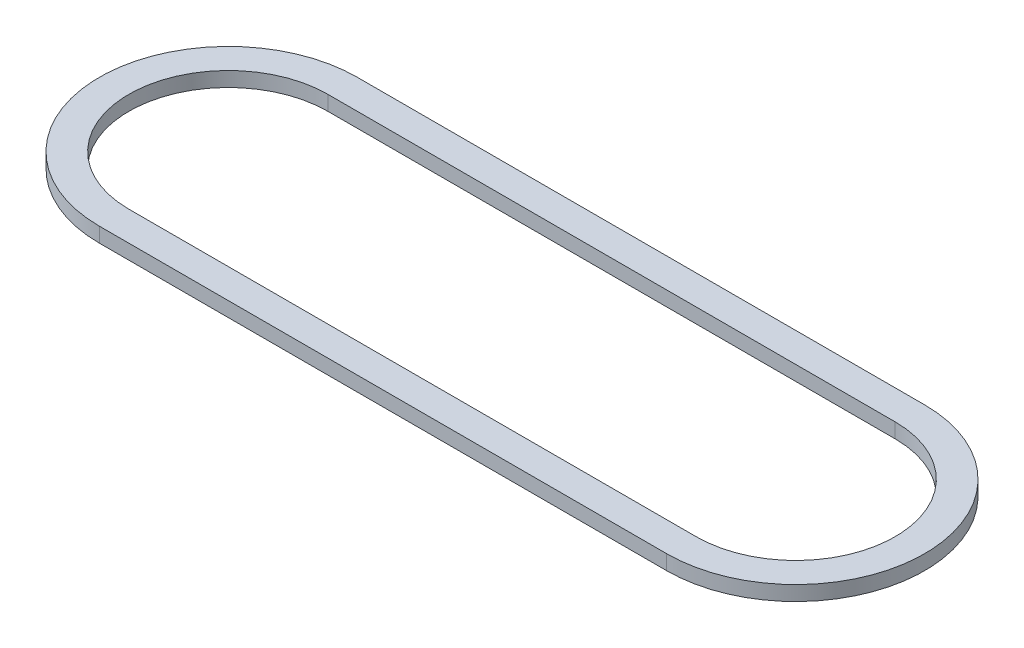
from build123d import *

# Parameters (mm, degrees)
BOSS_EXTRUDE1_DEPTH = 0.508


with BuildPart() as part:
    # Sketch1 → Boss-Extrude1 (new body)
    with BuildSketch(Plane(origin=(0, 0, 0), x_dir=(1, 0, 0), z_dir=(0, 1, 0))):
        with BuildLine():
            Line((-9.779, 4.445), (9.779, 4.445))
            ThreePointArc((9.779, 4.445), (14.224, 0), (9.779, -4.445))
            Line((9.779, -4.445), (-9.779, -4.445))
            ThreePointArc((-9.779, -4.445), (-14.224, 0), (-9.779, 4.445))
        make_face()
        with BuildLine():
            Line((-9.779, 3.429), (9.779, 3.429))
            ThreePointArc((9.779, 3.429), (13.208, 0), (9.779, -3.429))
            Line((9.779, -3.429), (-9.779, -3.429))
            ThreePointArc((-9.779, -3.429), (-13.208, 0), (-9.779, 3.429))
        make_face(mode=Mode.SUBTRACT)
    extrude(amount=BOSS_EXTRUDE1_DEPTH)


solid = part.part
